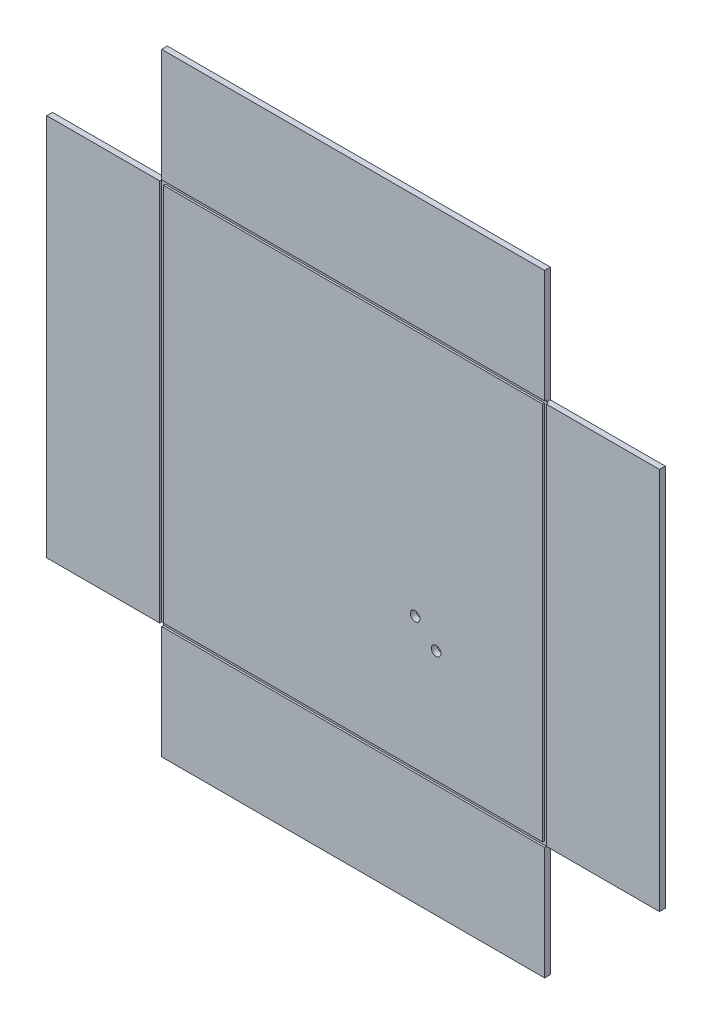
from build123d import *

# Parameters (mm, degrees)
ESQUISSE1_W                       = 320
ESQUISSE1_H                       = 320
BOSS_EXTRU_1_DEPTH                = 3
ENL_V_MAT_EXTRU_1_REACH           = 5
ESQUISSE2_W                       = 60
ESQUISSE2_H                       = 60
ESQUISSE3_W                       = 202
ESQUISSE3_H                       = 202
ESQUISSE3_W_2                     = 198
ESQUISSE3_H_2                     = 198
ENL_V_MAT_EXTRU_2_DEPTH           = 1
DIAM_TRE_DU_PER_AGE_5_0_5_1_D     = 5
DIAM_TRE_DU_PER_AGE_5_0_5_1_DEPTH = 3


with BuildPart() as part:
    # Esquisse1 → Boss.-Extru.1 (new body)
    with BuildSketch(Plane.XY):
        Rectangle(ESQUISSE1_W, ESQUISSE1_H)
    extrude(amount=BOSS_EXTRU_1_DEPTH)

    # Esquisse2 → Enlèv. mat.-Extru.1 (cut, up to next)
    with BuildSketch(Plane.XY.offset(3), mode=Mode.PRIVATE) as enl_v_mat_extru_1_sk1:
        with Locations((130, -130)):
            Rectangle(ESQUISSE2_W, ESQUISSE2_H)
    enl_v_mat_extru_1_tool1 = extrude(enl_v_mat_extru_1_sk1.sketch, amount=-ENL_V_MAT_EXTRU_1_REACH, mode=Mode.PRIVATE) & part.part
    add(enl_v_mat_extru_1_tool1.solids().sort_by_distance((130, -130, 3))[0], mode=Mode.SUBTRACT)
    # Esquisse2 → Enlèv. mat.-Extru.1 (cut, up to next)
    with BuildSketch(Plane.XY.offset(3), mode=Mode.PRIVATE) as enl_v_mat_extru_1_sk2:
        with Locations((-130, -130)):
            Rectangle(ESQUISSE2_W, ESQUISSE2_H)
    enl_v_mat_extru_1_tool2 = extrude(enl_v_mat_extru_1_sk2.sketch, amount=-ENL_V_MAT_EXTRU_1_REACH, mode=Mode.PRIVATE) & part.part
    add(enl_v_mat_extru_1_tool2.solids().sort_by_distance((-130, -130, 3))[0], mode=Mode.SUBTRACT)
    # Esquisse2 → Enlèv. mat.-Extru.1 (cut, up to next)
    with BuildSketch(Plane.XY.offset(3), mode=Mode.PRIVATE) as enl_v_mat_extru_1_sk3:
        with Locations((130, 130)):
            Rectangle(ESQUISSE2_W, ESQUISSE2_H)
    enl_v_mat_extru_1_tool3 = extrude(enl_v_mat_extru_1_sk3.sketch, amount=-ENL_V_MAT_EXTRU_1_REACH, mode=Mode.PRIVATE) & part.part
    add(enl_v_mat_extru_1_tool3.solids().sort_by_distance((130, 130, 3))[0], mode=Mode.SUBTRACT)
    # Esquisse2 → Enlèv. mat.-Extru.1 (cut, up to next)
    with BuildSketch(Plane.XY.offset(3), mode=Mode.PRIVATE) as enl_v_mat_extru_1_sk4:
        with Locations((-130, 130)):
            Rectangle(ESQUISSE2_W, ESQUISSE2_H)
    enl_v_mat_extru_1_tool4 = extrude(enl_v_mat_extru_1_sk4.sketch, amount=-ENL_V_MAT_EXTRU_1_REACH, mode=Mode.PRIVATE) & part.part
    add(enl_v_mat_extru_1_tool4.solids().sort_by_distance((-130, 130, 3))[0], mode=Mode.SUBTRACT)

    # Esquisse3 → Enlèv. mat.-Extru.2 (cut)
    with BuildSketch(Plane.XY.offset(3)):
        Rectangle(ESQUISSE3_W, ESQUISSE3_H)
        Rectangle(ESQUISSE3_W_2, ESQUISSE3_H_2, mode=Mode.SUBTRACT)
    extrude(amount=-ENL_V_MAT_EXTRU_2_DEPTH, mode=Mode.SUBTRACT)

    # Diamètre du perçage Ø5.0 (5)1
    with Locations(Plane.XY.offset(3)):
        with Locations((32.349968284, -30.166833461), (43.320273808, -40.396808862)):
            Hole(DIAM_TRE_DU_PER_AGE_5_0_5_1_D / 2, depth=DIAM_TRE_DU_PER_AGE_5_0_5_1_DEPTH)


solid = part.part
